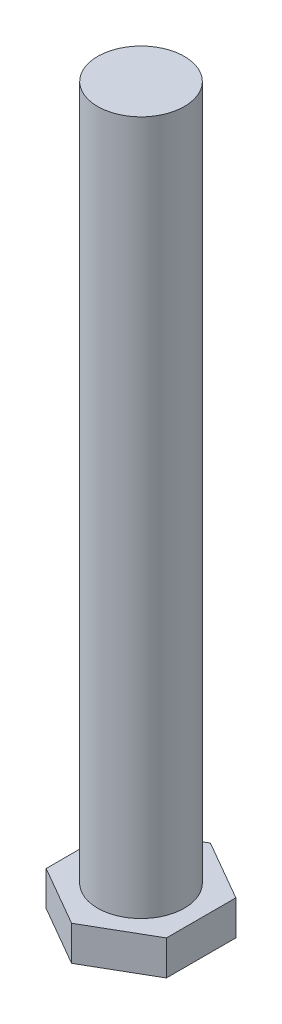
from build123d import *

# Parameters (mm, degrees)
SKETCH1_R           = 4
BOSS_EXTRUDE1_DEPTH = 2
SKETCH2_R           = 2.5
BOSS_EXTRUDE2_DEPTH = 40
SKETCH3_OUTSIDE_W   = 18.7
SKETCH3_OUTSIDE_H   = 18.7
CUT_EXTRUDE1_DEPTH  = 10


with BuildPart() as part:
    # Sketch1 → Boss-Extrude1 (new body)
    with BuildSketch(Plane(origin=(0, 0, 0), x_dir=(1, 0, 0), z_dir=(0, 1, 0))):
        Circle(SKETCH1_R)
    extrude(amount=BOSS_EXTRUDE1_DEPTH)

    # Sketch2 → Boss-Extrude2 (add)
    with BuildSketch(Plane(origin=(0, 2, 0), x_dir=(1, 0, 0), z_dir=(0, 1, 0))):
        Circle(SKETCH2_R)
    extrude(amount=BOSS_EXTRUDE2_DEPTH)

    # Sketch3 outside → Cut-Extrude1 (cut)
    with BuildSketch(Plane(origin=(0, 0, 0), x_dir=(-1, 0, 0), z_dir=(0, -1, 0))):
        Rectangle(SKETCH3_OUTSIDE_W, SKETCH3_OUTSIDE_H)
        Polygon((0, 4), (3.464101615, 2), (3.464101615, -2), (0, -4), (-3.464101615, -2), (-3.464101615, 2), align=None, mode=Mode.SUBTRACT)
    extrude(amount=-CUT_EXTRUDE1_DEPTH, mode=Mode.SUBTRACT)


solid = part.part
